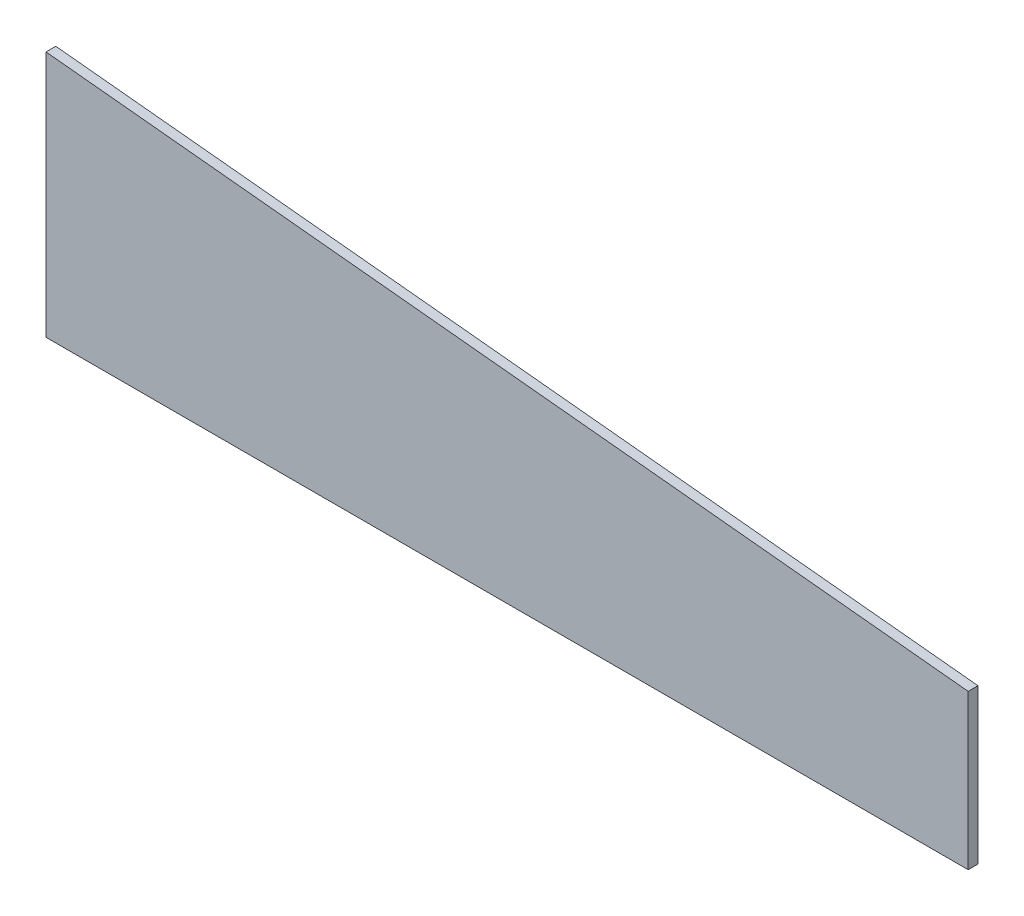
from build123d import *

# Parameters (mm, degrees)
BOSS_EXTRU_1_DEPTH = 1.5875


with BuildPart() as part:
    # Esquisse1 → Boss.-Extru.1 (new body)
    with BuildSketch(Plane.XY):
        Polygon((-149.248115566, 40), (-149.248115566, 0), (0, 0), (0, 25), align=None)
    extrude(amount=BOSS_EXTRU_1_DEPTH)


solid = part.part
